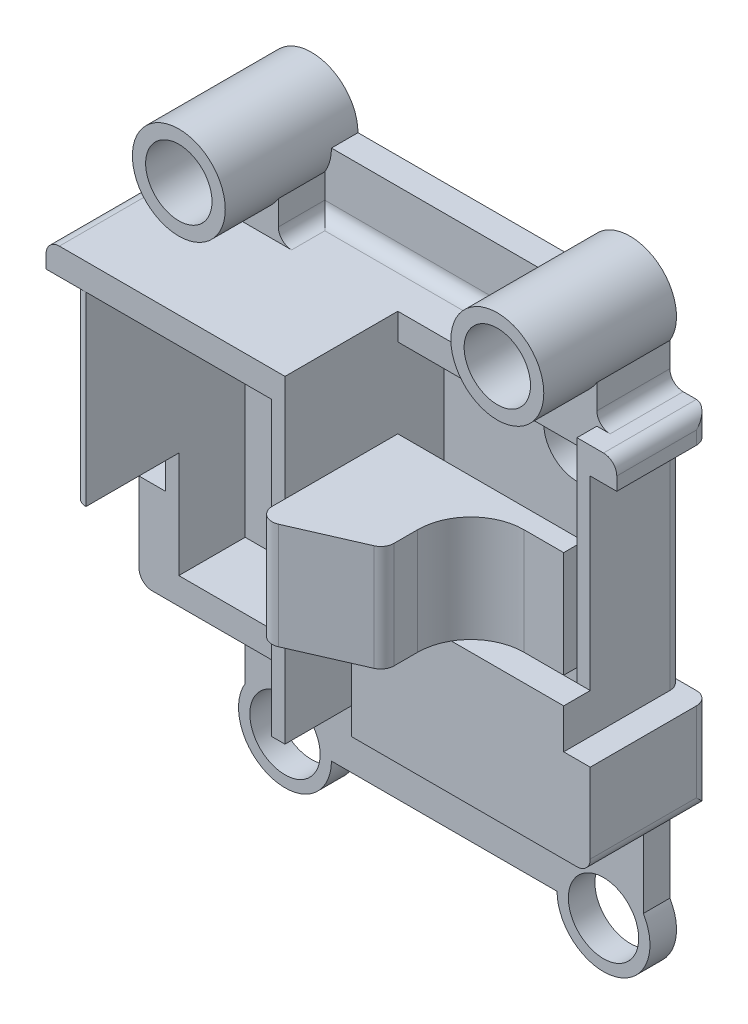
from build123d import *

# Parameters (mm, degrees)
SKETCH1_R            = 2.65
SKETCH1_R_2          = 2.650000000000013
BOSS_EXTRUDE1_DEPTH  = 2
BOSS_EXTRUDE2_DEPTH  = 12
CUT_EXTRUDE1_DEPTH   = 7
BOSS_EXTRUDE3_DEPTH  = 5
SKETCH6_R            = 3.4999999999999982
SKETCH6_R_2          = 2.4999999999999996
SKETCH6_R_3          = 3.4999999999999996
SKETCH6_R_4          = 2.4999999999999964
BOSS_EXTRUDE4_DEPTH  = 8
BOSS_EXTRUDE5_DEPTH  = 18
BOSS_EXTRUDE6_DEPTH  = 3.5
CUT_EXTRUDE2_DEPTH   = 1.5
SKETCH10_R           = 2.5000000000000004
CUT_EXTRUDE3_DEPTH   = 32.94135250736888
CUT_EXTRUDE4_DEPTH   = 33.74522866006589
FILLET1_R            = 1
BOSS_EXTRUDE7_DEPTH  = 11
CUT_EXTRUDE5_DEPTH   = 8
FILLET2_R            = 1
BOSS_EXTRUDE18_DEPTH = 7
FILLET3_R            = 4


with BuildPart() as part:
    # Sketch1 → Boss-Extrude1 (new body)
    with BuildSketch(Plane.XY):
        with BuildLine():
            Line((-14.999999999999993, 18.19722436226799), (-14.999999999999996, 15.350000000000001))
            Line((-14.999999999999996, 15.350000000000001), (-17.999999999999993, 15.350000000000001))
            Line((-17.999999999999993, 15.350000000000001), (-17.999999999999993, -10.649999999999999))
            Line((-17.999999999999993, -10.649999999999999), (-14.999999999999993, -10.649999999999999))
            Line((-14.999999999999993, -10.649999999999999), (-15.000000000000004, -18.197224362268003))
            ThreePointArc((-15.000000000000004, -18.197224362268003), (-12.935414346693491, -23.372684390808004), (-8.500000000000004, -20))
            Line((-8.500000000000004, -20), (8.499999999999996, -20))
            ThreePointArc((8.499999999999996, -20), (12.935414346693465, -23.37268439080802), (15.00000000000001, -18.197224362268035))
            Line((15.00000000000001, -18.197224362268035), (15.000000000000007, -10.649999999999995))
            Line((15.000000000000007, -10.649999999999995), (18.000000000000004, -10.649999999999995))
            Line((18.000000000000004, -10.649999999999995), (18.000000000000007, 15.350000000000005))
            Line((18.000000000000007, 15.350000000000005), (15.000000000000007, 15.350000000000005))
            Line((15.000000000000007, 15.350000000000005), (15.000000000000007, 18.197224362268017))
            ThreePointArc((15.000000000000007, 18.197224362268017), (12.935414346693479, 23.37268439080801), (8.5, 20))
            Line((8.5, 20), (-8.500000000000005, 19.999999999999996))
            ThreePointArc((-8.500000000000005, 19.999999999999996), (-12.935414346693495, 23.372684390808008), (-14.999999999999993, 18.19722436226799))
        make_face()
        with Locations((12, 20)):
            Circle(SKETCH1_R, mode=Mode.SUBTRACT)
        with Locations((11.999999999999996, -20.000000000000004)):
            Circle(SKETCH1_R, mode=Mode.SUBTRACT)
        with Locations((-12.000000000000004, 20)):
            Circle(SKETCH1_R, mode=Mode.SUBTRACT)
        with Locations((-12.000000000000004, -19.999999999999996)):
            Circle(SKETCH1_R_2, mode=Mode.SUBTRACT)
    extrude(amount=BOSS_EXTRUDE1_DEPTH)

    # Sketch2 → Boss-Extrude2 (add)
    with BuildSketch(Plane.XY.offset(2)):
        Polygon((-17.999999999999993, 15.350000000000001), (0, 15.350000000000001), (2.4e-16, 13.500000000000002), (2.82e-15, -7.499999999999996), (3.18e-15, -10.649999999999997), (-17.999999999999993, -10.649999999999999), align=None)
        Polygon((-0.9999999999999972, 13.350000000000001), (-14.99999999999999, 13.35), (-14.99999999999999, -8.649999999999999), (-0.9999999999999974, -8.649999999999999), align=None, mode=Mode.SUBTRACT)
    extrude(amount=BOSS_EXTRUDE2_DEPTH)

    # Sketch3 → Cut-Extrude1 (cut)
    with BuildSketch(Plane.XY.offset(14)):
        Polygon((-17.999999999999996, -0.6499999999999978), (-14.99999999999999, -0.6499999999999978), (-14.99999999999999, -8.649999999999999), (0, -8.649999999999999), (3.18e-15, -10.649999999999997), (-17.999999999999993, -10.649999999999999), align=None)
    extrude(amount=-CUT_EXTRUDE1_DEPTH, mode=Mode.SUBTRACT)

    # Sketch4 → Boss-Extrude3 (add)
    with BuildSketch(Plane.XY.offset(2)):
        Polygon((18.000000000000004, -10.649999999999995), (18.000000000000007, 15.350000000000005), (15.000000000000007, 15.350000000000005), (0, 15.350000000000001), (2.5e-16, 13.350000000000003), (15.000000000000004, 13.350000000000003), (15.000000000000007, -7.649999999999994), (12.000000000000007, -10.649999999999995), align=None)
        Polygon((3.18e-15, -10.649999999999997), (3.000000000000003, -10.649999999999997), (0, -7.649999999999994), align=None)
    extrude(amount=BOSS_EXTRUDE3_DEPTH)

    # Sketch6 → Boss-Extrude4 (add)
    # profile 1 of 2: a face of its own
    with BuildSketch(Plane.XY.offset(2)):
        with Locations(Location((12, 20, 0), (0, 0, 180))):
            Circle(SKETCH6_R)
        with Locations((12, 20)):
            Circle(SKETCH6_R_2, mode=Mode.SUBTRACT)
    # profile 2 of 2: a face of its own
    with BuildSketch(Plane.XY.offset(2)):
        with Locations((-12.000000000000004, 20)):
            Circle(SKETCH6_R_3)
        with Locations((-12.000000000000004, 20)):
            Circle(SKETCH6_R_4, mode=Mode.SUBTRACT)
    extrude(amount=BOSS_EXTRUDE4_DEPTH)

    # Sketch7 → Boss-Extrude5 (add)
    with BuildSketch(Plane(origin=(18.000000000000004, -2.4e-15, 0), x_dir=(0, 0, -1), z_dir=(1, -1.3e-16, 0))):
        Polygon((-7, -10.649999999999993), (-9.000000000000002, -10.649999999999997), (-9.000000000000002, -0.649999999999996), (-7, -0.649999999999996), align=None)
    extrude(amount=-BOSS_EXTRUDE5_DEPTH)

    # Sketch8 → Boss-Extrude6 (add)
    with BuildSketch(Plane.XY.offset(2)):
        with BuildLine():
            Line((-14.999999999999993, 18.19722436226799), (-14.999999999999996, 15.350000000000001))
            Line((-14.999999999999996, 15.350000000000001), (-9.000000000000005, 15.350000000000005))
            Line((-9.000000000000005, 15.350000000000005), (-9.000000000000005, 18.197224362268006))
            ThreePointArc((-9.000000000000005, 18.197224362268006), (-11.999999999999993, 16.5), (-14.999999999999993, 18.19722436226799))
        make_face()
        with BuildLine():
            Line((15.000000000000005, 18.197224362268017), (15.000000000000007, 15.350000000000005))
            Line((15.000000000000007, 15.350000000000005), (9.107416754268383, 15.350000000000005))
            Line((9.107416754268383, 15.350000000000005), (9.107416754268383, 18.02947667699346))
            ThreePointArc((9.107416754268383, 18.02947667699346), (12.099596241159652, 16.501417345731724), (15.000000000000005, 18.197224362268017))
        make_face()
    extrude(amount=BOSS_EXTRUDE6_DEPTH)

    # Sketch9 → Cut-Extrude2 (cut)
    with BuildSketch(Plane.XY.offset(7)):
        Polygon((0, 15.350000000000001), (15.000000000000004, 15.350000000000001), (15.000000000000004, 13.350000000000003), (2.5e-16, 13.350000000000003), align=None)
    extrude(amount=-CUT_EXTRUDE2_DEPTH, mode=Mode.SUBTRACT)

    # Sketch10 → Cut-Extrude3 (cut, through all)
    with BuildSketch(Plane.XY.offset(2)):
        with Locations((10, 10)):
            Circle(SKETCH10_R)
    extrude(amount=-CUT_EXTRUDE3_DEPTH, mode=Mode.SUBTRACT)

    # Sketch11 → Cut-Extrude4 (cut, through all)
    with BuildSketch(Plane.XY.offset(14)):
        Polygon((-17.999999999999993, 13.350000000000001), (-15.999999999999986, 13.350000000000001), (-15.999999999999986, -3.6500000000000004), (-17.99999999999999, -3.6500000000000004), align=None)
        Polygon((18.000000000000004, 13.350000000000003), (16, 13.350000000000005), (16.000000000000007, -3.649999999999997), (18.000000000000007, -3.649999999999997), align=None)
    extrude(amount=-CUT_EXTRUDE4_DEPTH, mode=Mode.SUBTRACT)

    # Fillet1
    fillet1_edges = [part.edges().sort_by_distance(p)[0] for p in [
        (13.500000000000007, -10.649999999999995, 2),
        (18.000000000000004, -7.149999999999996, 0),
        (-9.000000000000005, 15.350000000000005, 3.75),
        (0.0537083771341873, 15.350000000000003, 2),
        (9.107416754268383, 15.350000000000005, 3.75),
        (-17.999999999999993, 14.350000000000001, 0),
        (18.000000000000007, 14.350000000000005, 0),
        (-17.999999999999993, -7.149999999999999, 0),
        (-15.999999999999986, 6.350000000000001, 14),
        (-15.999999999999986, 4.850000000000001, 0),
        (16.000000000000004, 4.850000000000005, 0),
        (-14.999999999999996, 15.350000000000001, 2.75),
        (15.000000000000007, 15.350000000000005, 2.75),
        (18.000000000000007, 15.350000000000005, 3.5),
        (18.000000000000004, -10.649999999999997, 4.500000000000001),
        (15.000000000000007, -10.649999999999995, 1),
        (-14.999999999999993, -10.649999999999999, 1),
        (-17.999999999999993, 15.350000000000001, 7),
        (-5.999999999999995, -10.649999999999999, 2),
        (-17.999999999999993, -10.649999999999999, 3.5),
    ]]
    fillet(fillet1_edges, radius=FILLET1_R)


with BuildPart() as body_2:
    # Sketch12 → Boss-Extrude7 (new body)
    with BuildSketch(Plane.XY.offset(5.5)):
        Polygon((3.05e-15, 7.350000000000004), (7.0000000000000036, 7.350000000000004), (7.0000000000000036, -0.649999999999996), (2.7e-16, -0.6499999999999972), align=None)
    extrude(amount=BOSS_EXTRUDE7_DEPTH)

    # Sketch16 → Cut-Extrude5 (cut)
    with BuildSketch(Plane(origin=(0, 7.350000000000004, 0), x_dir=(1, 0, 0), z_dir=(0, 1, 0))):
        Polygon((16.000000000000007, -9.500000000000002), (3.05e-15, -16.5), (16.000000000000007, -16.5), align=None)
    extrude(amount=-CUT_EXTRUDE5_DEPTH, mode=Mode.SUBTRACT)

    # Fillet2
    fillet2_edges = [body_2.edges().sort_by_distance(p)[0] for p in [
        (7.0000000000000036, 3.350000000000004, 13.437500000000002),
        (1.66e-15, 3.3500000000000036, 16.5),
    ]]
    fillet(fillet2_edges, radius=FILLET2_R)

    # Sketch19 → Boss-Extrude18 (add)
    with BuildSketch(Plane(origin=(7.0000000000000036, 0, 0), x_dir=(0, 0, -1), z_dir=(1, 0, 0))):
        Polygon((-5.5, 7.350000000000004), (-6.999999999999999, 7.350000000000004), (-6.999999999999998, -0.649999999999996), (-5.499999999999999, -0.649999999999996), align=None)
    extrude(amount=BOSS_EXTRUDE18_DEPTH)

    # Fillet3
    fillet3_edges = [body_2.edges().sort_by_distance(p)[0] for p in [
        (7.0000000000000036, 3.350000000000004, 6.999999999999998),
    ]]
    fillet(fillet3_edges, radius=FILLET3_R)


solid = Compound([part.part, body_2.part])
